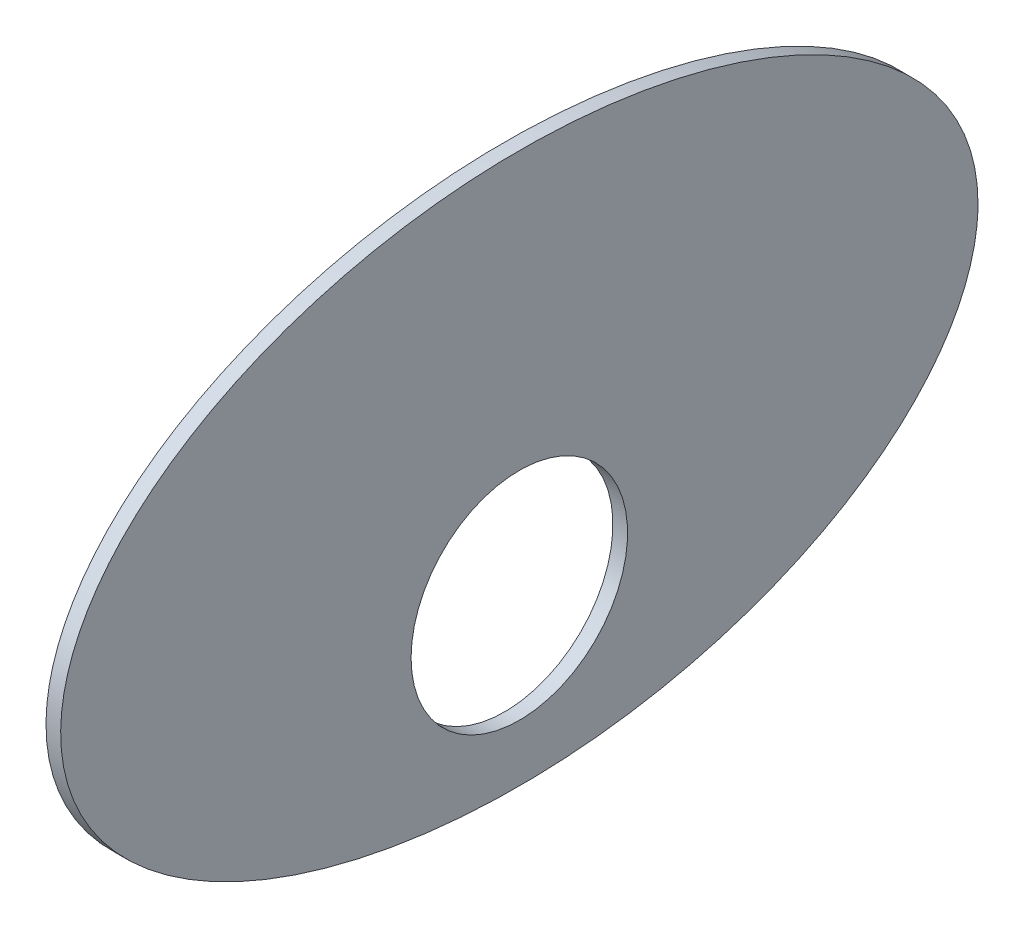
from build123d import *

# Parameters (mm, degrees)
SKETCH1_RX          = 125
SKETCH1_RY          = 75
BOSS_EXTRUDE1_DEPTH = 4
SKETCH2_R           = 29.5
CUT_EXTRUDE1_DEPTH  = 5


with BuildPart() as part:
    # Sketch1 → Boss-Extrude1 (new body)
    with BuildSketch(Plane(origin=(0, 0, 0), x_dir=(0, 0, -1), z_dir=(1, 0, 0))):
        with Locations((0, 0)):
            Ellipse(SKETCH1_RX, SKETCH1_RY)
    extrude(amount=BOSS_EXTRUDE1_DEPTH)

    # Sketch2 → Cut-Extrude1 (cut, through all)
    with BuildSketch(Plane.ZY):
        with Locations((0, -30)):
            Circle(SKETCH2_R)
    extrude(amount=-CUT_EXTRUDE1_DEPTH, mode=Mode.SUBTRACT)


solid = part.part
